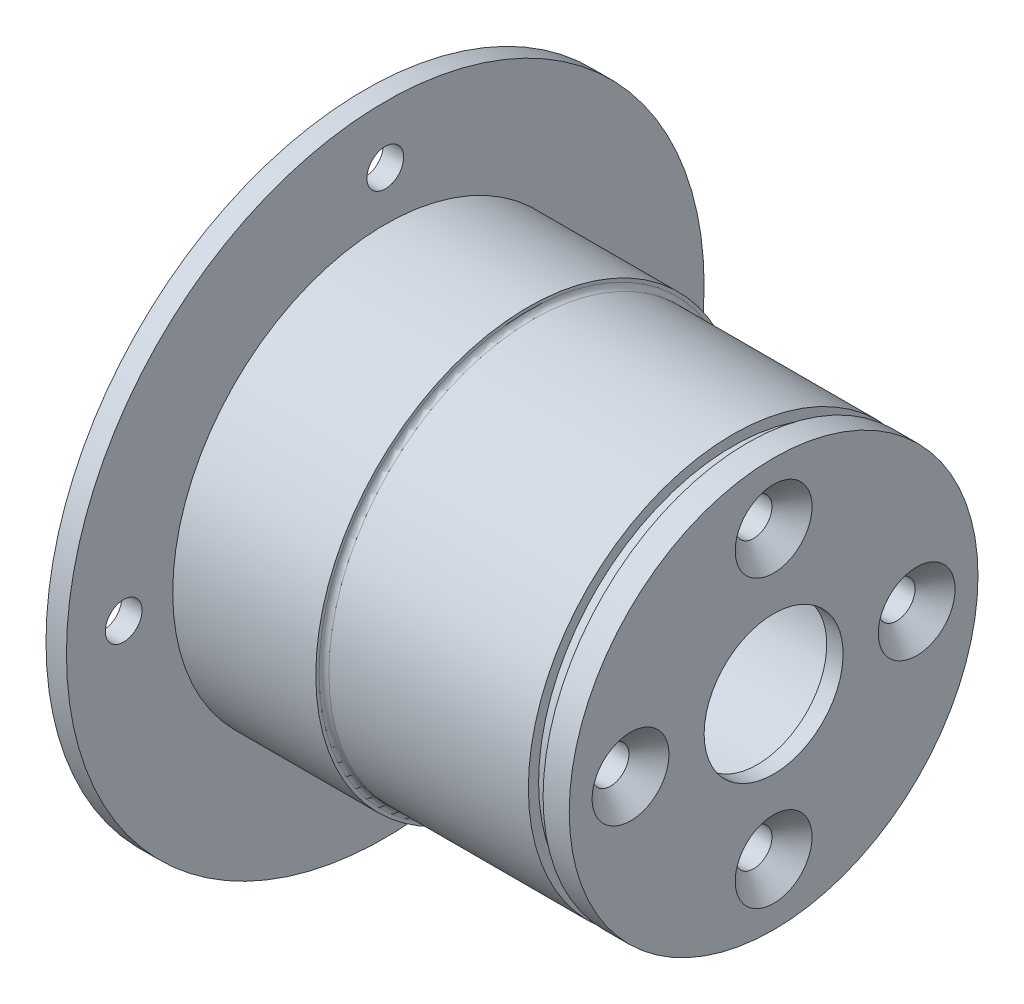
from build123d import *

# Parameters (mm, degrees)
CSK_FOR_M4_FLAT_HEAD_MACHINE_SCREW1_D           = 4.5
CSK_FOR_M4_FLAT_HEAD_MACHINE_SCREW1_DEPTH       = 15
CSK_FOR_M4_FLAT_HEAD_MACHINE_SCREW1_CSINK_D     = 9.4
CSK_FOR_M4_FLAT_HEAD_MACHINE_SCREW1_CSINK_ANGLE = 90
FILLET1_R                                       = 0.6
SKETCH9_R                                       = 25
SKETCH9_R_2                                     = 23.75
CUT_EXTRUDE1_DEPTH                              = 1.8
M4_CLEARANCE_HOLE1_D                            = 4.5
M4_CLEARANCE_HOLE1_DEPTH                        = 2.5


with BuildPart() as part:
    # Sketch2 → Revolve1 (revolve)
    with BuildSketch(Plane.XY):
        Polygon((0, 21), (35, 21), (35, 12.5), (48, 12.5), (48, 8.5), (50, 8.5), (50, 25), (20, 25), (20, 26), (2.5, 26), (2.5, 39), (0, 39), (0, 26), align=None)
    revolve(axis=Axis((-64.103352454, 0, 0), (1, 0, 0)))

    # CSK for M4 Flat Head Machine Screw1
    with Locations(Plane(origin=(50, 0, 0), x_dir=(0, 0, -1), z_dir=(1, 0, 0))):
        with Locations((0, 17.5), (17.5, 0), (0, -17.5), (-17.5, 0)):
            CounterSinkHole(CSK_FOR_M4_FLAT_HEAD_MACHINE_SCREW1_D / 2, CSK_FOR_M4_FLAT_HEAD_MACHINE_SCREW1_CSINK_D / 2, depth=CSK_FOR_M4_FLAT_HEAD_MACHINE_SCREW1_DEPTH, counter_sink_angle=CSK_FOR_M4_FLAT_HEAD_MACHINE_SCREW1_CSINK_ANGLE)

    # Fillet1
    fillet1_edges = [part.edges().sort_by_distance(p)[0] for p in [
        (20, -25, 0),
    ]]
    fillet(fillet1_edges, radius=FILLET1_R)

    # Sketch9 → Cut-Extrude1 (cut)
    with BuildSketch(Plane(origin=(45, 0, 0), x_dir=(0, 0, -1), z_dir=(1, 0, 0))):
        Circle(SKETCH9_R)
        Circle(SKETCH9_R_2, mode=Mode.SUBTRACT)
    extrude(amount=CUT_EXTRUDE1_DEPTH, mode=Mode.SUBTRACT)

    # M4 Clearance Hole1
    with Locations(Plane.ZY):
        with Locations((0, 32), (0, -32), (32, 0), (-32, 0)):
            Hole(M4_CLEARANCE_HOLE1_D / 2, depth=M4_CLEARANCE_HOLE1_DEPTH)


solid = part.part
